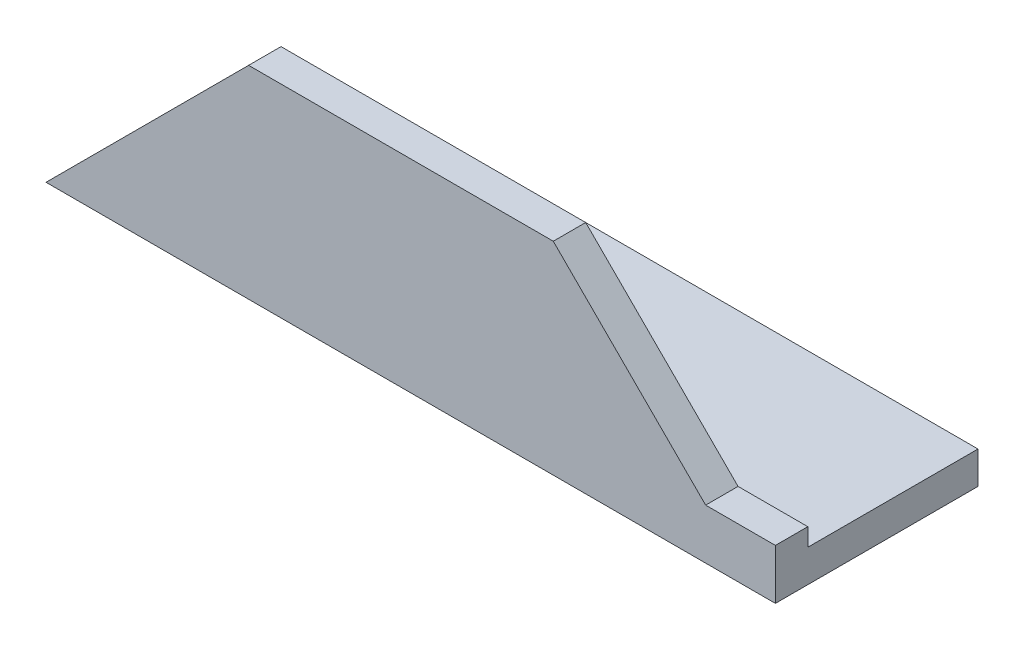
from build123d import *

# Parameters (mm, degrees)
EXTRUDE_1_DEPTH     = 90
CUT_EXTRUDE_1_DEPTH = 26


with BuildPart() as part:
    # Эскиз1 → Вытянуть-Тонкостенный1 (new body)
    with BuildSketch(Plane(origin=(0, 0, 0), x_dir=(0, 0, -1), z_dir=(1, 0, 0))):
        Polygon((0, 25), (0, 0), (25, 0), (25, 4), (4, 4), (4, 25), align=None)
    extrude(amount=EXTRUDE_1_DEPTH)

    # Эскиз2 → Вырез-Вытянуть1 (cut, through all)
    with BuildSketch(Plane.XY):
        Polygon((0, 0), (0, 25), (25, 25), align=None)
        Polygon((90, 6.199303699), (81.394610848, 6.199303699), (62.593914547, 25), (90, 25), align=None)
    extrude(amount=-CUT_EXTRUDE_1_DEPTH, mode=Mode.SUBTRACT)


solid = part.part
